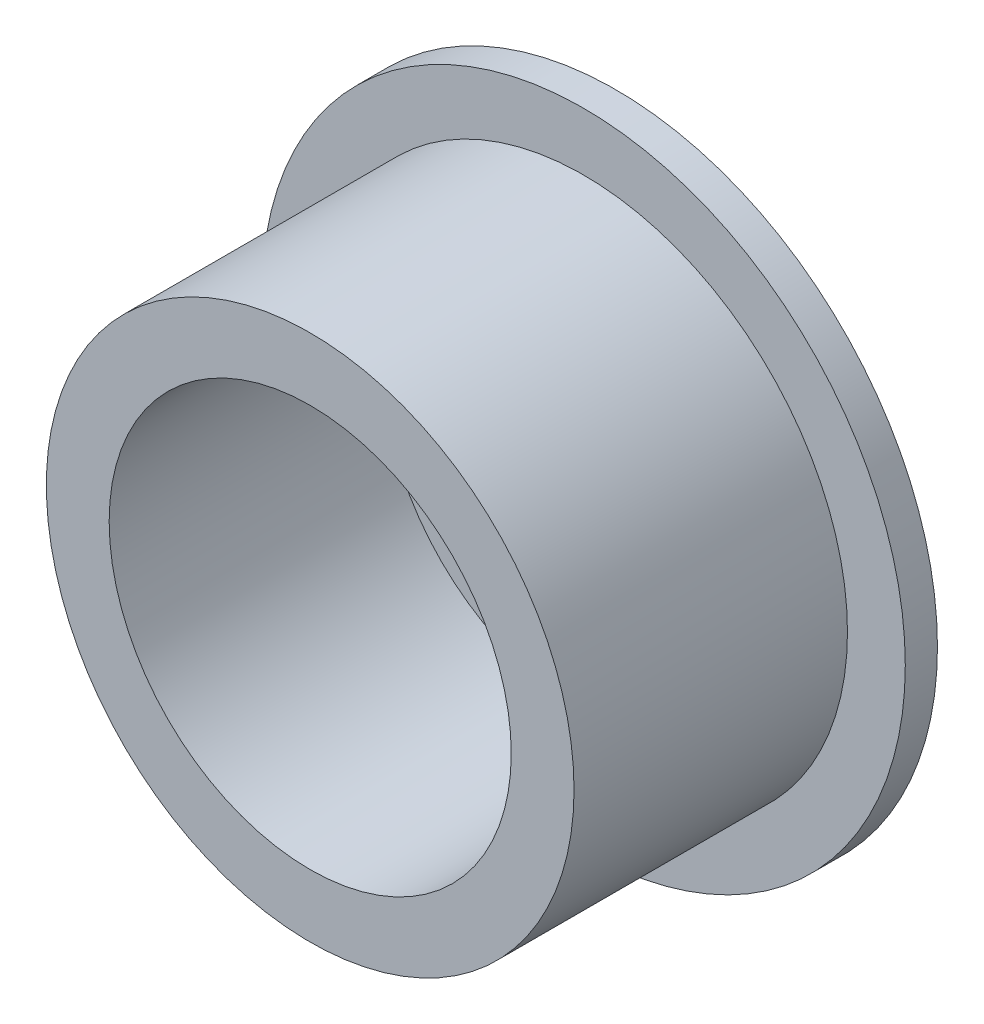
from build123d import *

# Parameters (mm, degrees)
SKETCH1_R           = 20
SKETCH1_R_2         = 1.5
BOSS_EXTRUDE1_DEPTH = 2
SKETCH2_R           = 16.405
SKETCH2_R_2         = 12.5
BOSS_EXTRUDE2_DEPTH = 17
SKETCH4_R           = 7.62
CUT_EXTRUDE1_DEPTH  = 17


with BuildPart() as part:
    # Sketch1 → Boss-Extrude1 (new body)
    with BuildSketch(Plane.XY):
        Circle(SKETCH1_R)
        with Locations((0, 10)):
            Circle(SKETCH1_R_2, mode=Mode.SUBTRACT)
        with Locations((10, 0)):
            Circle(SKETCH1_R_2, mode=Mode.SUBTRACT)
        with Locations((0, -10)):
            Circle(SKETCH1_R_2, mode=Mode.SUBTRACT)
        with Locations((-10, 0)):
            Circle(SKETCH1_R_2, mode=Mode.SUBTRACT)
    extrude(amount=BOSS_EXTRUDE1_DEPTH)

    # Sketch2 → Boss-Extrude2 (add)
    with BuildSketch(Plane.XY.offset(2)):
        Circle(SKETCH2_R)
        Circle(SKETCH2_R_2, mode=Mode.SUBTRACT)
    extrude(amount=BOSS_EXTRUDE2_DEPTH)

    # Sketch4 → Cut-Extrude1 (cut)
    with BuildSketch(Plane(origin=(0, 0, 0), x_dir=(-1, 0, 0), z_dir=(0, 0, -1))):
        Circle(SKETCH4_R)
    extrude(amount=-CUT_EXTRUDE1_DEPTH, mode=Mode.SUBTRACT)


solid = part.part
